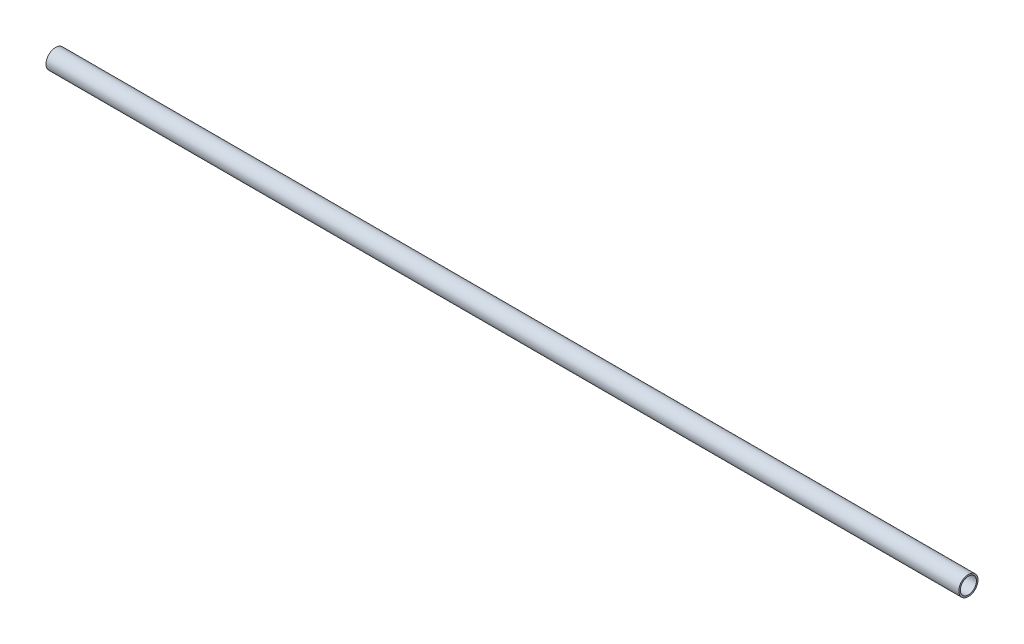
from build123d import *

# Parameters (mm, degrees)
SKETCH1_R           = 3.175
SKETCH1_R_2         = 2.667
BOSS_EXTRUDE1_DEPTH = 301.625


with BuildPart() as part:
    # Sketch1 → Boss-Extrude1 (new body)
    with BuildSketch(Plane(origin=(0, 0, 0), x_dir=(0, 0, -1), z_dir=(1, 0, 0))):
        Circle(SKETCH1_R)
        Circle(SKETCH1_R_2, mode=Mode.SUBTRACT)
    extrude(amount=-BOSS_EXTRUDE1_DEPTH)


solid = part.part
